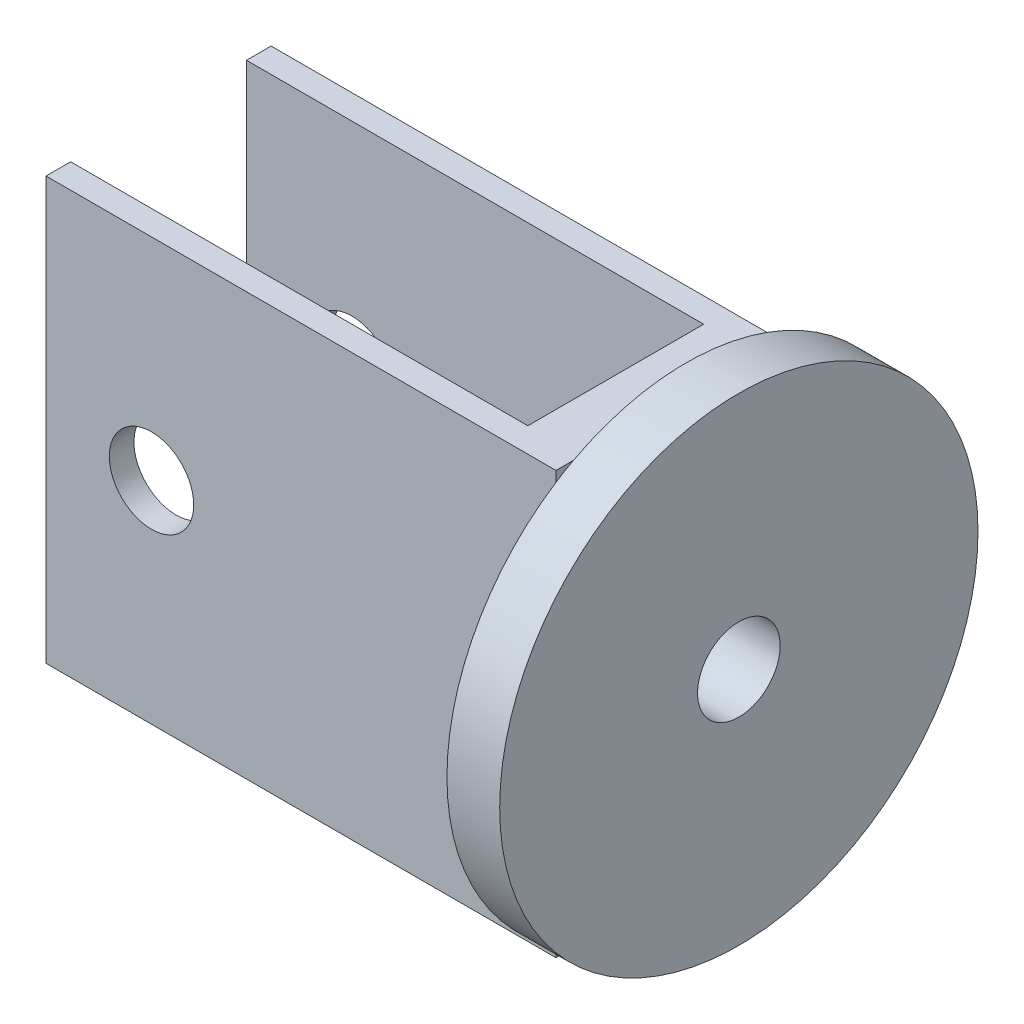
from build123d import *

# Parameters (mm, degrees)
BOSS_EXTRUDE1_DEPTH         = 240
SKETCH5_R                   = 136
BOSS_EXTRUDE2_DEPTH         = 30
IZIM1_R                     = 23.5
KES_EKSTR_ZYON1_DEPTH       = 80
IZIM2_R                     = 25
IZIM2_R_2                   = 10
Y_KSEKLIK_EKSTR_ZYON1_DEPTH = 10
SCALE1_SCALE                = 0.25
SKETCH6_R                   = 6
CUT_EXTRUDE1_DEPTH          = 200


with BuildPart() as part:
    # Sketch1 → Boss-Extrude1 (new body)
    with BuildSketch(Plane(origin=(0, 0, 0), x_dir=(1, 0, 0), z_dir=(0, 1, 0))):
        Polygon((0, -20), (0, -6), (290, -6), (290, -134), (0, -134), (0, -120), (260, -120), (260, -20), align=None)
    extrude(amount=BOSS_EXTRUDE1_DEPTH)

    # Sketch5 → Boss-Extrude2 (add)
    with BuildSketch(Plane(origin=(290, 0, 0), x_dir=(0, 0, -1), z_dir=(1, 0, 0))):
        with Locations((-60, 120)):
            Circle(SKETCH5_R)
    extrude(amount=BOSS_EXTRUDE2_DEPTH)

    # Çizim1 → Kes-Ekstrüzyon1 (cut)
    with BuildSketch(Plane(origin=(320, 0, 0), x_dir=(0, 0, -1), z_dir=(1, 0, 0))):
        with Locations((-60, 120)):
            Circle(IZIM1_R)
    extrude(amount=-KES_EKSTR_ZYON1_DEPTH, mode=Mode.SUBTRACT)

    # Çizim2 → Yükseklik-Ekstrüzyon1 (add)
    with BuildSketch(Plane.ZY.offset(-260)):
        with Locations((60, 120)):
            Circle(IZIM2_R)
        with Locations((60, 120)):
            Circle(IZIM2_R_2, mode=Mode.SUBTRACT)
    extrude(amount=-Y_KSEKLIK_EKSTR_ZYON1_DEPTH)


with BuildPart() as part_1:
    # Scale1: scaled about (228.089824151, 120, 66.174750275)
    add(part.part.scale(SCALE1_SCALE).moved(Location((171.067368113, 90, 49.631062706))))

    # Sketch6 → Cut-Extrude1 (cut)
    with BuildSketch(Plane.XY.offset(83.131062707)):
        with Locations((186.067368113, 120)):
            Circle(SKETCH6_R)
    extrude(amount=-CUT_EXTRUDE1_DEPTH, mode=Mode.SUBTRACT)


solid = part_1.part
